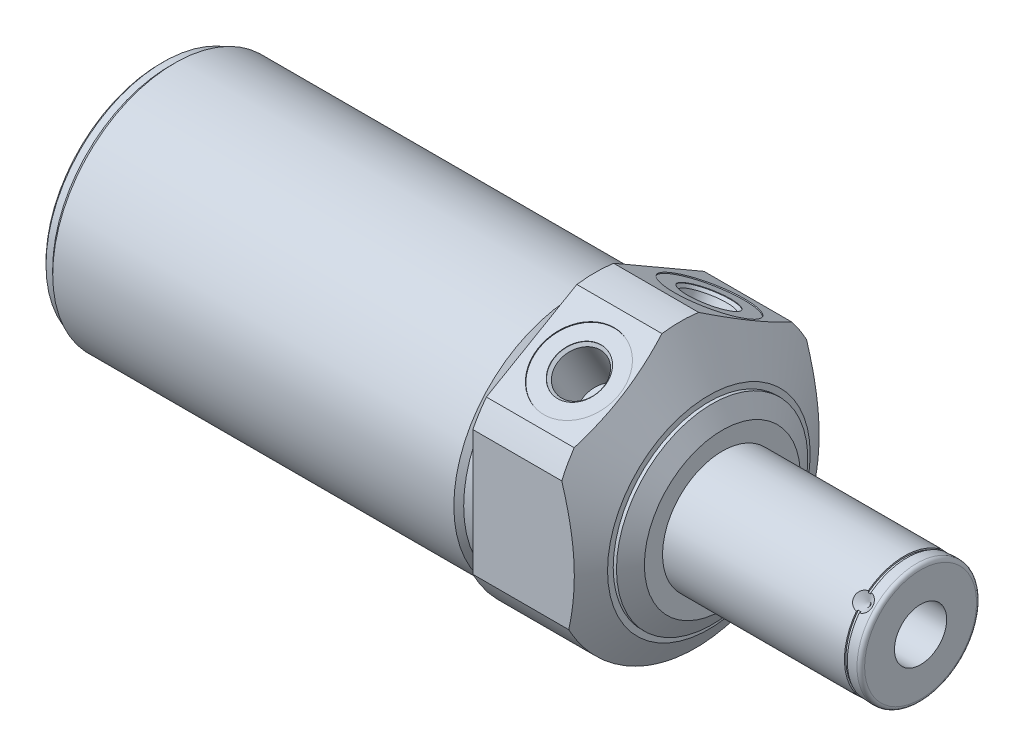
from build123d import *

# Parameters (mm, degrees)
SKETCH1_R           = 40
EXTRUDE1_DEPTH      = 33.7566
EXTRUDE1_DEPTH_BACK = 115.4684
CUT_EXTRUDE1_REACH  = 117.468
SKETCH2_R           = 40
SKETCH2_R_2         = 32.4231
SKETCH4_R           = 40
CUT_EXTRUDE3_DEPTH  = 33.7566
CHAMFER1_SIZE       = 0.762
CIRPATTERN1_COUNT   = 4
SKETCH21_W          = 0.762
SKETCH21_H          = 0.381


with BuildPart() as part:
    # Sketch1 → Extrude1 (new body, two sides)
    with BuildSketch(Plane(origin=(0, 0, 0), x_dir=(0, 0, -1), z_dir=(1, 0, 0))) as extrude1_sk:
        Circle(SKETCH1_R)
    extrude(amount=EXTRUDE1_DEPTH)
    extrude(extrude1_sk.sketch, amount=-EXTRUDE1_DEPTH_BACK)

    # Sketch2 → Cut-Extrude1 (cut, up to next)
    with BuildSketch(Plane(origin=(0, 0, 0), x_dir=(0, 0, -1), z_dir=(1, 0, 0)), mode=Mode.PRIVATE) as cut_extrude1_sk1:
        Circle(SKETCH2_R)
        with Locations((0, -3.556)):
            Circle(SKETCH2_R_2, mode=Mode.SUBTRACT)
    cut_extrude1_tool1 = extrude(cut_extrude1_sk1.sketch, amount=-CUT_EXTRUDE1_REACH, mode=Mode.PRIVATE) & part.part
    add(cut_extrude1_tool1.solids().sort_by_distance((0, 0, 38.868629))[0], mode=Mode.SUBTRACT)

    # Sketch4 → Cut-Extrude3 (cut)
    with BuildSketch(Plane.ZY.offset(-33.7566)):
        Circle(SKETCH4_R)
        with BuildLine():
            Line((32.4993, -16.642059841), (32.4993, 16.642059841))
            ThreePointArc((32.4993, 16.642059841), (30.829989478, 19.562065459), (28.899060011, 22.316070146))
            Line((28.899060011, 22.316070146), (4.876753653, 36.185355188))
            ThreePointArc((4.876753653, 36.185355188), (0, 36.5125), (-4.876753653, 36.185355188))
            Line((-4.876753653, 36.185355188), (-28.899060011, 22.316070146))
            ThreePointArc((-28.899060011, 22.316070146), (-30.829989478, 19.562065459), (-32.4993, 16.642059841))
            Line((-32.4993, 16.642059841), (-32.4993, -16.642059841))
            ThreePointArc((-32.4993, -16.642059841), (0, -36.5125), (32.4993, -16.642059841))
        make_face(mode=Mode.SUBTRACT)
    extrude(amount=CUT_EXTRUDE3_DEPTH, mode=Mode.SUBTRACT)

    # Sketch6 → Cut-Revolve2 (revolve, cut)
    with BuildSketch(Plane.XY, mode=Mode.PRIVATE) as cut_revolve2_sk:
        Polygon((16.840814463, 46.444), (30.1752, 23.348166762), (30.1752, 21.844), (31.043631085, 21.844), (33.7566, 17.145), (33.7566, 46.444), align=None)
    revolve(cut_revolve2_sk.sketch.rotate(Axis((1.987224567, -3.556, 0), (1, 0, 0)), 90), axis=Axis((1.987224567, -3.556, 0), (1, 0, 0)), mode=Mode.SUBTRACT)  # turned: the seam where the file's is

    # S2D0002 → Cut-Revolve3 (revolve, cut)
    with BuildSketch(Plane(origin=(13.0048, 13.712414668, 8.609072086), x_dir=(0, 0.422618262, -0.906307787), z_dir=(1, 0, 0))):
        Polygon((5.209143222, 17.863962689), (9.28298182, 18.220377383), (9.260844261, 18.473410837), (-1.442470814, 17.536992106), (-0.185057482, 3.164691957), (5.735925326, 3.68271083), (4.573703496, 16.966967129), (5.220212001, 17.737445962), align=None)
    cut_revolve3 = revolve(axis=Axis((13.0048, 2.878131243, 2.248277721), (0, 0.866025404, 0.5)), mode=Mode.SUBTRACT)

    # Mirror1: Cut-Revolve3 across plane
    add(cut_revolve3.mirror(Plane.XY), mode=Mode.SUBTRACT)

    # Sketch10 → Cut-Revolve6 (revolve, cut)
    with BuildSketch(Plane.XY, mode=Mode.PRIVATE) as cut_revolve6_sk:
        Polygon((0, 28.8671), (0, 27.559), (-3.81, 27.559), (-5.1181, 28.8671), align=None)
    revolve(cut_revolve6_sk.sketch.rotate(Axis((-5.09397, -3.556, 0), (1, 0, 0)), 90), axis=Axis((-5.09397, -3.556, 0), (1, 0, 0)), mode=Mode.SUBTRACT)  # turned: the seam where the file's is

    # Sketch12 → Cut-Revolve8 (revolve, cut)
    with BuildSketch(Plane.XY, mode=Mode.PRIVATE) as cut_revolve8_sk:
        Polygon((-115.4684, 28.8671), (-115.4684, 27.559), (-112.9284, 27.559), (-111.6203, 28.8671), align=None)
    revolve(cut_revolve8_sk.sketch.rotate(Axis((-50.92827, -3.556, 0), (1, 0, 0)), 90), axis=Axis((-50.92827, -3.556, 0), (1, 0, 0)), mode=Mode.SUBTRACT)  # turned: the seam where the file's is

    # Chamfer1
    chamfer1_edges = [part.edges().sort_by_distance(p)[0] for p in [
        (-115.4684, -3.556, -31.115),
    ]]
    chamfer(chamfer1_edges, length=CHAMFER1_SIZE)

    # Sketch13 → Revolve1 (revolve)
    with BuildSketch(Plane.XY, mode=Mode.PRIVATE) as revolve1_sk:
        with BuildLine():
            Line((33.7566, -3.556), (86.386, -3.556))
            Line((86.386, -3.556), (86.386, -18.415))
            ThreePointArc((86.386, -18.415), (86.08842049, -19.13342049), (85.37, -19.431))
            Line((85.37, -19.431), (33.7566, -19.431))
            Line((33.7566, -19.431), (33.7566, -3.556))
        make_face()
    revolve(revolve1_sk.sketch.rotate(Axis((4.7498, -3.556, 0), (1, 0, 0)), 270), axis=Axis((4.7498, -3.556, 0), (1, 0, 0)))  # turned: the seam where the file's is

    # S2D0001 → Cut-Revolve9 (revolve, cut)
    with BuildSketch(Plane.XY, mode=Mode.PRIVATE) as cut_revolve9_sk:
        Polygon((86.386, 3.3782), (60.986, 3.3782), (56.819512296, -3.556), (86.386, -3.556), align=None)
    revolve(cut_revolve9_sk.sketch.rotate(Axis((-2.8067, -3.556, 0), (-1, 0, 0)), 270), axis=Axis((-2.8067, -3.556, 0), (-1, 0, 0)), mode=Mode.SUBTRACT)  # turned: the seam where the file's is

    # Sketch16 → Cut-Revolve10 (revolve, cut)
    with BuildSketch(Plane(origin=(0, -6.070471714, 2.514471714), x_dir=(1, 0, 0), z_dir=(0, -0.707106781, -0.707106781)), mode=Mode.PRIVATE) as cut_revolve10_sk:
        Polygon((82.4236, -19.431), (80.0106, -19.431), (82.4236, -17.018), align=None)
    cut_revolve10 = revolve(cut_revolve10_sk.sketch.rotate(Axis((82.4236, -3.610591198, 0.054591198), (0, -0.707106781, 0.707106781)), 270), axis=Axis((82.4236, -3.610591198, 0.054591198), (0, -0.707106781, 0.707106781)), mode=Mode.SUBTRACT)  # turned: the seam where the file's is

    # CirPattern1: Cut-Revolve10 ×4 about axis
    cirpattern1_axis = Axis((4.7498, -3.556, 0), (-1, 0, 0))
    for i in range(1, CIRPATTERN1_COUNT):
        add(cut_revolve10.rotate(cirpattern1_axis, i * 360 / CIRPATTERN1_COUNT), mode=Mode.SUBTRACT)

    # Sketch21 → Cut-Revolve11 (revolve, cut)
    with BuildSketch(Plane.XY, mode=Mode.PRIVATE) as cut_revolve11_sk:
        with Locations((82.4236, 12.1285)):
            Rectangle(SKETCH21_W, SKETCH21_H)
    revolve(cut_revolve11_sk.sketch.rotate(Axis((23.873488058, -3.556, 0), (1, 0, 0)), 90), axis=Axis((23.873488058, -3.556, 0), (1, 0, 0)), mode=Mode.SUBTRACT)  # turned: the seam where the file's is


solid = part.part
